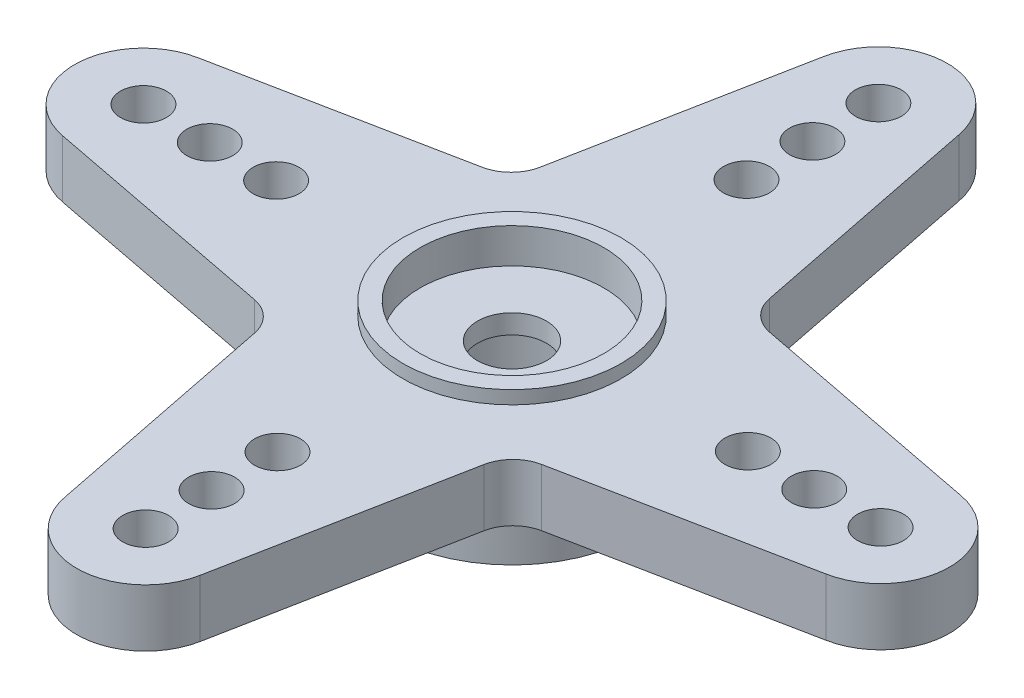
from build123d import *

# Parameters (mm, degrees)
SKETCH1_R           = 1.190625
SKETCH1_R_2         = 0.79375
BOSS_EXTRUDE1_DEPTH = 1.984375
SKETCH2_R           = 3.175
CUT_EXTRUDE1_DEPTH  = 0.7493
SKETCH3_R           = 4.365625
BOSS_EXTRUDE2_DEPTH = 2.3876
SKETCH4_R           = 2.778125
CUT_EXTRUDE2_DEPTH  = 2.9591
SKETCH5_R           = 3.7703125
SKETCH5_R_2         = 3.175
BOSS_EXTRUDE3_DEPTH = 0.4572


with BuildPart() as part:
    # Sketch1 → Boss-Extrude1 (new body)
    with BuildSketch(Plane(origin=(0, 0, 0), x_dir=(1, 0, 0), z_dir=(0, 1, 0))):
        with BuildLine():
            Line((-3.96335347, 4.938233395), (-2.375942501, 13.151798758))
            ThreePointArc((-2.375942501, 13.151798758), (-0.037956575, 15.081193279), (2.300029351, 13.151798758))
            Line((2.300029351, 13.151798758), (3.933761069, 4.9618349))
            ThreePointArc((3.933761069, 4.9618349), (4.283887399, 4.309571692), (4.938233395, 3.96335347))
            Line((4.938233395, 3.96335347), (13.151798758, 2.375942501))
            ThreePointArc((13.151798758, 2.375942501), (15.081193279, 0.037956575), (13.151798758, -2.300029351))
            Line((13.151798758, -2.300029351), (4.9618349, -3.933761069))
            ThreePointArc((4.9618349, -3.933761069), (4.309571692, -4.283887399), (3.96335347, -4.938233395))
            Line((3.96335347, -4.938233395), (2.375942501, -13.151798758))
            ThreePointArc((2.375942501, -13.151798758), (0.037956575, -15.081193279), (-2.300029351, -13.151798758))
            Line((-2.300029351, -13.151798758), (-3.933761069, -4.9618349))
            ThreePointArc((-3.933761069, -4.9618349), (-4.283887399, -4.309571692), (-4.938233395, -3.96335347))
            Line((-4.938233395, -3.96335347), (-13.151798758, -2.375942501))
            ThreePointArc((-13.151798758, -2.375942501), (-15.081193279, -0.037956575), (-13.151798758, 2.300029351))
            Line((-13.151798758, 2.300029351), (-4.9618349, 3.933761069))
            ThreePointArc((-4.9618349, 3.933761069), (-4.309571692, 4.283887399), (-3.96335347, 4.938233395))
        make_face()
        Circle(SKETCH1_R, mode=Mode.SUBTRACT)
        with Locations((-0.037956575, 12.699943279)):
            Circle(SKETCH1_R_2, mode=Mode.SUBTRACT)
        with Locations((-0.031124391, 10.413953489)):
            Circle(SKETCH1_R_2, mode=Mode.SUBTRACT)
        with Locations((-0.024292208, 8.127963699)):
            Circle(SKETCH1_R_2, mode=Mode.SUBTRACT)
        with Locations((12.699943279, 0.037956575)):
            Circle(SKETCH1_R_2, mode=Mode.SUBTRACT)
        with Locations((10.413953489, 0.031124391)):
            Circle(SKETCH1_R_2, mode=Mode.SUBTRACT)
        with Locations((8.127963699, 0.024292208)):
            Circle(SKETCH1_R_2, mode=Mode.SUBTRACT)
        with Locations((0.037956575, -12.699943279)):
            Circle(SKETCH1_R_2, mode=Mode.SUBTRACT)
        with Locations((0.031124391, -10.413953489)):
            Circle(SKETCH1_R_2, mode=Mode.SUBTRACT)
        with Locations((0.024292208, -8.127963699)):
            Circle(SKETCH1_R_2, mode=Mode.SUBTRACT)
        with Locations((-12.699943279, -0.037956575)):
            Circle(SKETCH1_R_2, mode=Mode.SUBTRACT)
        with Locations((-10.413953489, -0.031124391)):
            Circle(SKETCH1_R_2, mode=Mode.SUBTRACT)
        with Locations((-8.127963699, -0.024292208)):
            Circle(SKETCH1_R_2, mode=Mode.SUBTRACT)
    extrude(amount=BOSS_EXTRUDE1_DEPTH)

    # Sketch2 → Cut-Extrude1 (cut)
    with BuildSketch(Plane(origin=(0, 1.984375, 0), x_dir=(1, 0, 0), z_dir=(0, 1, 0))):
        Circle(SKETCH2_R)
    extrude(amount=-CUT_EXTRUDE1_DEPTH, mode=Mode.SUBTRACT)

    # Sketch3 → Boss-Extrude2 (add)
    with BuildSketch(Plane.XZ):
        Circle(SKETCH3_R)
    extrude(amount=BOSS_EXTRUDE2_DEPTH)

    # Sketch4 → Cut-Extrude2 (cut)
    with BuildSketch(Plane.XZ.offset(2.3876)):
        Circle(SKETCH4_R)
    extrude(amount=-CUT_EXTRUDE2_DEPTH, mode=Mode.SUBTRACT)

    # Sketch5 → Boss-Extrude3 (add)
    with BuildSketch(Plane(origin=(0, 1.984375, 0), x_dir=(1, 0, 0), z_dir=(0, 1, 0))):
        Circle(SKETCH5_R)
        Circle(SKETCH5_R_2, mode=Mode.SUBTRACT)
    extrude(amount=BOSS_EXTRUDE3_DEPTH)


solid = part.part
